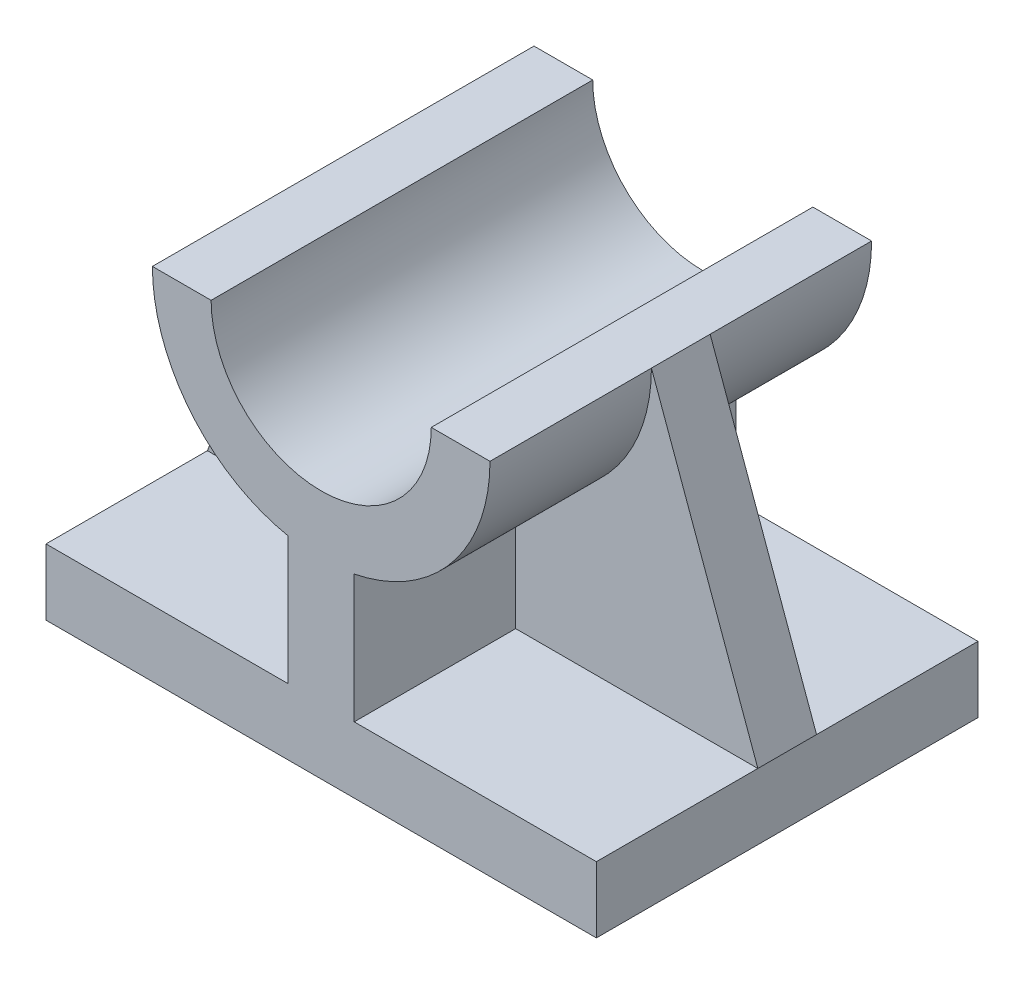
from build123d import *

# Parameters (mm, degrees)
BOSS_EXTRUDE1_DEPTH = 26
RIB1_REACH          = 65.738
SKETCH3_WALL_W      = 172.022520638
SKETCH3_WALL_H      = 8


with BuildPart() as part:
    # Sketch2 → Boss-Extrude1 (new, symmetric)
    with BuildSketch(Plane.XY):
        with BuildLine():
            Line((-23, 44.5), (-15, 44.5))
            ThreePointArc((-15, 44.5), (0, 29.5), (15, 44.5))
            Line((15, 44.5), (23, 44.5))
            ThreePointArc((23, 44.5), (17.783419244, 29.914047854), (4.5, 21.944512863))
            Line((4.5, 21.944512863), (4.5, 4.5))
            Line((4.5, 4.5), (37.5, 4.5))
            Line((37.5, 4.5), (37.5, -4.5))
            Line((37.5, -4.5), (-37.5, -4.5))
            Line((-37.5, -4.5), (-37.5, 4.5))
            Line((-37.5, 4.5), (-4.5, 4.5))
            Line((-4.5, 4.5), (-4.5, 21.944512863))
            ThreePointArc((-4.5, 21.944512863), (-17.783419244, 29.914047854), (-23, 44.5))
        make_face()
    extrude(amount=BOSS_EXTRUDE1_DEPTH, both=True)

    # Sketch3 wall → Rib1 (add, up to next)
    with BuildSketch(Plane(origin=(30.25, 24.5, 0), x_dir=(0.340799323621, -0.940136065162, 0), z_dir=(0.940136065162, 0.340799323621, 0)), mode=Mode.PRIVATE) as rib1_sk1:
        Rectangle(SKETCH3_WALL_W, SKETCH3_WALL_H)
    rib1_tool1 = extrude(rib1_sk1.sketch, amount=-RIB1_REACH, mode=Mode.PRIVATE) - part.part
    rib1 = rib1_tool1.solids().sort_by_distance((30.25, 24.5, 0))[0]
    add(rib1)

    # Mirror1: Rib1 across plane
    add(rib1.mirror(Plane(origin=(0, 0, 0), x_dir=(0, 0, 1), z_dir=(1, 0, 0))))


solid = part.part
